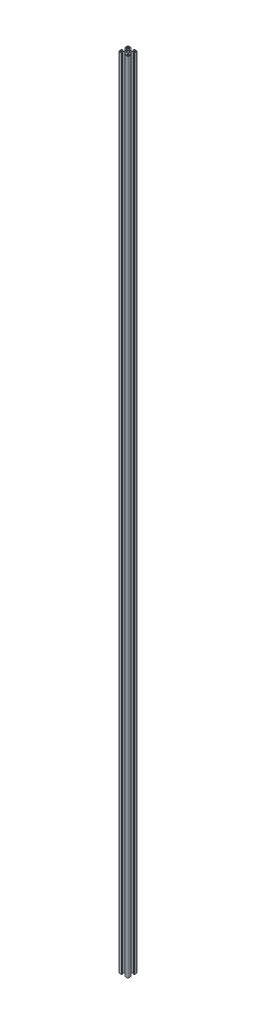
from build123d import *

# Parameters (mm, degrees)
SKETCH_3_R      = 3.4
EXTRUDE_1_DEPTH = 2554


with BuildPart() as part:
    # 草图3 → 凸台-拉伸1 (new body)
    with BuildSketch(Plane(origin=(0, 0, 0), x_dir=(1, 0, 0), z_dir=(0, 1, 0))):
        with BuildLine():
            Line((-15, -12.5), (-15, -5.4))
            ThreePointArc((-15, -5.4), (-14.941421356, -5.258578644), (-14.8, -5.2))
            Line((-14.8, -5.2), (-14.4, -5.2))
            ThreePointArc((-14.4, -5.2), (-14.258578644, -5.141421356), (-14.2, -5))
            Line((-14.2, -5), (-14.2, -4.3))
            ThreePointArc((-14.2, -4.3), (-14.141421356, -4.158578644), (-14, -4.1))
            Line((-14, -4.1), (-13.2, -4.1))
            Line((-13.2, -4.1), (-13.2, -8.25))
            Line((-13.2, -8.25), (-9.522792206, -8.25))
            Line((-9.522792206, -8.25), (-5.8, -4.527207794))
            Line((-5.8, -4.527207794), (-5.8, 4.527207794))
            Line((-5.8, 4.527207794), (-9.522792206, 8.25))
            Line((-9.522792206, 8.25), (-13.2, 8.25))
            Line((-13.2, 8.25), (-13.2, 4.1))
            Line((-13.2, 4.1), (-14, 4.1))
            ThreePointArc((-14, 4.1), (-14.141421356, 4.158578644), (-14.2, 4.3))
            Line((-14.2, 4.3), (-14.2, 5))
            ThreePointArc((-14.2, 5), (-14.258578644, 5.141421356), (-14.4, 5.2))
            Line((-14.4, 5.2), (-14.8, 5.2))
            ThreePointArc((-14.8, 5.2), (-14.941421356, 5.258578644), (-15, 5.4))
            Line((-15, 5.4), (-15, 12.5))
            ThreePointArc((-15, 12.5), (-14.267766953, 14.267766953), (-12.5, 15))
            Line((-12.5, 15), (-5.4, 15))
            ThreePointArc((-5.4, 15), (-5.258578644, 14.941421356), (-5.2, 14.8))
            Line((-5.2, 14.8), (-5.2, 14.4))
            ThreePointArc((-5.2, 14.4), (-5.141421356, 14.258578644), (-5, 14.2))
            Line((-5, 14.2), (-4.3, 14.2))
            ThreePointArc((-4.3, 14.2), (-4.158578644, 14.141421356), (-4.1, 14))
            Line((-4.1, 14), (-4.1, 13.2))
            Line((-4.1, 13.2), (-8.25, 13.2))
            Line((-8.25, 13.2), (-8.25, 9.522792206))
            Line((-8.25, 9.522792206), (-4.527207794, 5.8))
            Line((-4.527207794, 5.8), (4.527207794, 5.8))
            Line((4.527207794, 5.8), (8.25, 9.522792206))
            Line((8.25, 9.522792206), (8.25, 13.2))
            Line((8.25, 13.2), (4.1, 13.2))
            Line((4.1, 13.2), (4.1, 14))
            ThreePointArc((4.1, 14), (4.158578644, 14.141421356), (4.3, 14.2))
            Line((4.3, 14.2), (5, 14.2))
            ThreePointArc((5, 14.2), (5.141421356, 14.258578644), (5.2, 14.4))
            Line((5.2, 14.4), (5.2, 14.8))
            ThreePointArc((5.2, 14.8), (5.258578644, 14.941421356), (5.4, 15))
            Line((5.4, 15), (12.5, 15))
            ThreePointArc((12.5, 15), (14.267766953, 14.267766953), (15, 12.5))
            Line((15, 12.5), (15, 5.4))
            ThreePointArc((15, 5.4), (14.941421356, 5.258578644), (14.8, 5.2))
            Line((14.8, 5.2), (14.4, 5.2))
            ThreePointArc((14.4, 5.2), (14.258578644, 5.141421356), (14.2, 5))
            Line((14.2, 5), (14.2, 4.3))
            ThreePointArc((14.2, 4.3), (14.141421356, 4.158578644), (14, 4.1))
            Line((14, 4.1), (13.2, 4.1))
            Line((13.2, 4.1), (13.2, 8.25))
            Line((13.2, 8.25), (9.522792206, 8.25))
            Line((9.522792206, 8.25), (5.8, 4.527207794))
            Line((5.8, 4.527207794), (5.8, -4.527207794))
            Line((5.8, -4.527207794), (9.522792206, -8.25))
            Line((9.522792206, -8.25), (13.2, -8.25))
            Line((13.2, -8.25), (13.2, -4.1))
            Line((13.2, -4.1), (14, -4.1))
            ThreePointArc((14, -4.1), (14.141421356, -4.158578644), (14.2, -4.3))
            Line((14.2, -4.3), (14.2, -5))
            ThreePointArc((14.2, -5), (14.258578644, -5.141421356), (14.4, -5.2))
            Line((14.4, -5.2), (14.8, -5.2))
            ThreePointArc((14.8, -5.2), (14.941421356, -5.258578644), (15, -5.4))
            Line((15, -5.4), (15, -12.5))
            ThreePointArc((15, -12.5), (14.267766953, -14.267766953), (12.5, -15))
            Line((12.5, -15), (5.4, -15))
            ThreePointArc((5.4, -15), (5.258578644, -14.941421356), (5.2, -14.8))
            Line((5.2, -14.8), (5.2, -14.4))
            ThreePointArc((5.2, -14.4), (5.141421356, -14.258578644), (5, -14.2))
            Line((5, -14.2), (4.3, -14.2))
            ThreePointArc((4.3, -14.2), (4.158578644, -14.141421356), (4.1, -14))
            Line((4.1, -14), (4.1, -13.2))
            Line((4.1, -13.2), (8.25, -13.2))
            Line((8.25, -13.2), (8.25, -9.522792206))
            Line((8.25, -9.522792206), (4.527207794, -5.8))
            Line((4.527207794, -5.8), (-4.527207794, -5.8))
            Line((-4.527207794, -5.8), (-8.25, -9.522792206))
            Line((-8.25, -9.522792206), (-8.25, -13.2))
            Line((-8.25, -13.2), (-4.1, -13.2))
            Line((-4.1, -13.2), (-4.1, -14))
            ThreePointArc((-4.1, -14), (-4.158578644, -14.141421356), (-4.3, -14.2))
            Line((-4.3, -14.2), (-5, -14.2))
            ThreePointArc((-5, -14.2), (-5.141421356, -14.258578644), (-5.2, -14.4))
            Line((-5.2, -14.4), (-5.2, -14.8))
            ThreePointArc((-5.2, -14.8), (-5.258578644, -14.941421356), (-5.4, -15))
            Line((-5.4, -15), (-12.5, -15))
            ThreePointArc((-12.5, -15), (-14.267766953, -14.267766953), (-15, -12.5))
        make_face()
        Circle(SKETCH_3_R, mode=Mode.SUBTRACT)
        with BuildLine():
            Line((-13.2, -12.2), (-13.2, -11.05))
            ThreePointArc((-13.2, -11.05), (-12.907106781, -10.342893219), (-12.2, -10.05))
            Line((-12.2, -10.05), (-11.05, -10.05))
            ThreePointArc((-11.05, -10.05), (-10.342893219, -10.342893219), (-10.05, -11.05))
            Line((-10.05, -11.05), (-10.05, -12.2))
            ThreePointArc((-10.05, -12.2), (-10.342893219, -12.907106781), (-11.05, -13.2))
            Line((-11.05, -13.2), (-12.2, -13.2))
            ThreePointArc((-12.2, -13.2), (-12.907106781, -12.907106781), (-13.2, -12.2))
        make_face(mode=Mode.SUBTRACT)
        with BuildLine():
            Line((-10.05, 12.2), (-10.05, 11.05))
            ThreePointArc((-10.05, 11.05), (-10.342893219, 10.342893219), (-11.05, 10.05))
            Line((-11.05, 10.05), (-12.2, 10.05))
            ThreePointArc((-12.2, 10.05), (-12.907106781, 10.342893219), (-13.2, 11.05))
            Line((-13.2, 11.05), (-13.2, 12.2))
            ThreePointArc((-13.2, 12.2), (-12.907106781, 12.907106781), (-12.2, 13.2))
            Line((-12.2, 13.2), (-11.05, 13.2))
            ThreePointArc((-11.05, 13.2), (-10.342893219, 12.907106781), (-10.05, 12.2))
        make_face(mode=Mode.SUBTRACT)
        with BuildLine():
            Line((13.2, 12.2), (13.2, 11.05))
            ThreePointArc((13.2, 11.05), (12.907106781, 10.342893219), (12.2, 10.05))
            Line((12.2, 10.05), (11.05, 10.05))
            ThreePointArc((11.05, 10.05), (10.342893219, 10.342893219), (10.05, 11.05))
            Line((10.05, 11.05), (10.05, 12.2))
            ThreePointArc((10.05, 12.2), (10.342893219, 12.907106781), (11.05, 13.2))
            Line((11.05, 13.2), (12.2, 13.2))
            ThreePointArc((12.2, 13.2), (12.907106781, 12.907106781), (13.2, 12.2))
        make_face(mode=Mode.SUBTRACT)
        with BuildLine():
            Line((10.05, -12.2), (10.05, -11.05))
            ThreePointArc((10.05, -11.05), (10.342893219, -10.342893219), (11.05, -10.05))
            Line((11.05, -10.05), (12.2, -10.05))
            ThreePointArc((12.2, -10.05), (12.907106781, -10.342893219), (13.2, -11.05))
            Line((13.2, -11.05), (13.2, -12.2))
            ThreePointArc((13.2, -12.2), (12.907106781, -12.907106781), (12.2, -13.2))
            Line((12.2, -13.2), (11.05, -13.2))
            ThreePointArc((11.05, -13.2), (10.342893219, -12.907106781), (10.05, -12.2))
        make_face(mode=Mode.SUBTRACT)
    extrude(amount=EXTRUDE_1_DEPTH)


solid = part.part
